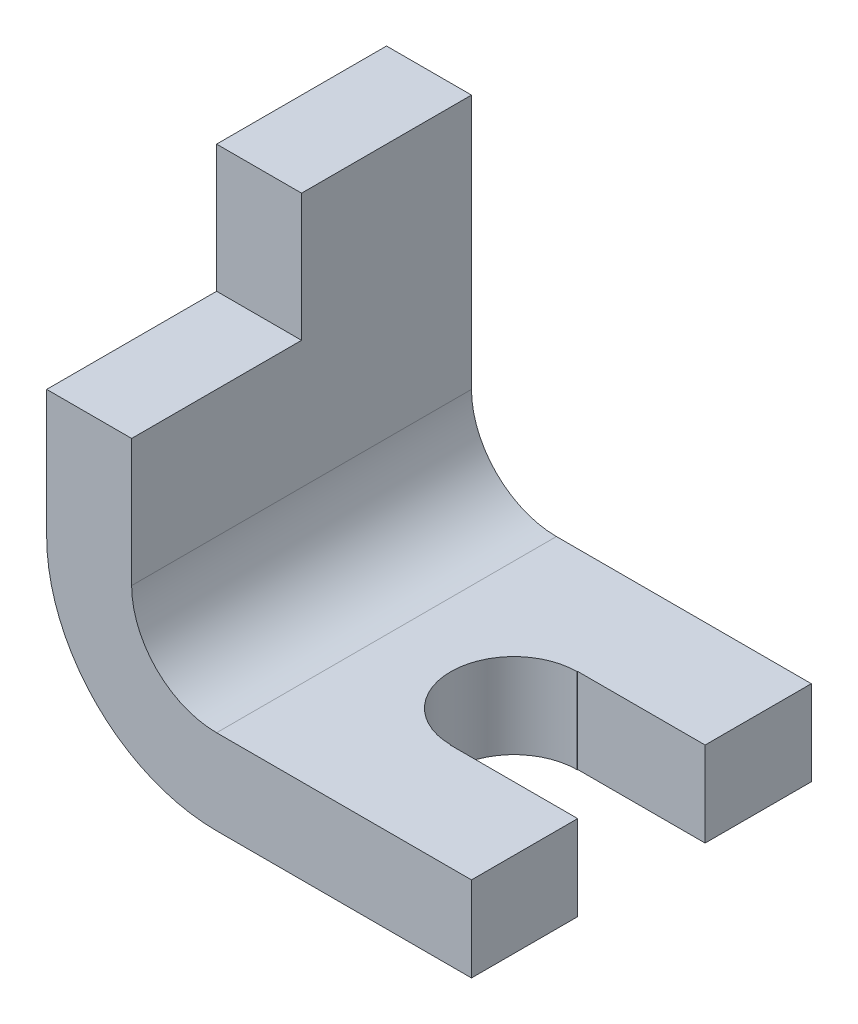
from build123d import *

# Parameters (mm, degrees)
BOSS_EXTRUDE1_DEPTH     = 40
SKETCH3_W               = 20
SKETCH3_H               = 15
CUT_EXTRUDE1_DEPTH      = 10
CUT_EXTRUDE5_DEPTH      = 41
CUT_EXTRUDE5_DEPTH_BACK = 10


with BuildPart() as part:
    # Sketch1 → Boss-Extrude1 (new body)
    with BuildSketch(Plane.XY):
        with BuildLine():
            Line((20, 0), (50, 0))
            Line((50, 0), (50, 10))
            Line((50, 10), (20, 10))
            ThreePointArc((20, 10), (12.928932188, 12.928932188), (10, 20))
            Line((10, 20), (10, 50))
            Line((10, 50), (0, 50))
            Line((0, 50), (0, 20))
            ThreePointArc((0, 20), (5.857864376, 5.857864376), (20, 0))
        make_face()
    extrude(amount=-BOSS_EXTRUDE1_DEPTH)

    # Sketch3 → Cut-Extrude1 (cut)
    with BuildSketch(Plane(origin=(10, 0, 0), x_dir=(0, 0, -1), z_dir=(1, 0, 0))):
        with Locations((10, 42.5)):
            Rectangle(SKETCH3_W, SKETCH3_H)
    extrude(amount=-CUT_EXTRUDE1_DEPTH, mode=Mode.SUBTRACT)

    # Sketch4 → Cut-Extrude5 (cut, two sides)
    with BuildSketch(Plane(origin=(0, 10, 0), x_dir=(1, 0, 0), z_dir=(0, 1, 0))) as cut_extrude5_sk:
        with BuildLine():
            Line((174.127122105, 27.5), (50, 27.5))
            Line((50, 27.5), (35, 27.5))
            Line((35, 27.5), (35, 27.448852076))
            ThreePointArc((35, 27.448852076), (27.551147924, 20), (35, 12.551147924))
            Line((35, 12.551147924), (35, 12.5))
            Line((35, 12.5), (50, 12.5))
            Line((50, 12.5), (174.127122105, 12.5))
            Line((174.127122105, 12.5), (422.381366315, 12.5))
            Line((422.381366315, 12.5), (422.381366315, 27.5))
            Line((422.381366315, 27.5), (174.127122105, 27.5))
        make_face()
    extrude(amount=CUT_EXTRUDE5_DEPTH, mode=Mode.SUBTRACT)
    extrude(cut_extrude5_sk.sketch, amount=-CUT_EXTRUDE5_DEPTH_BACK, mode=Mode.SUBTRACT)


solid = part.part
